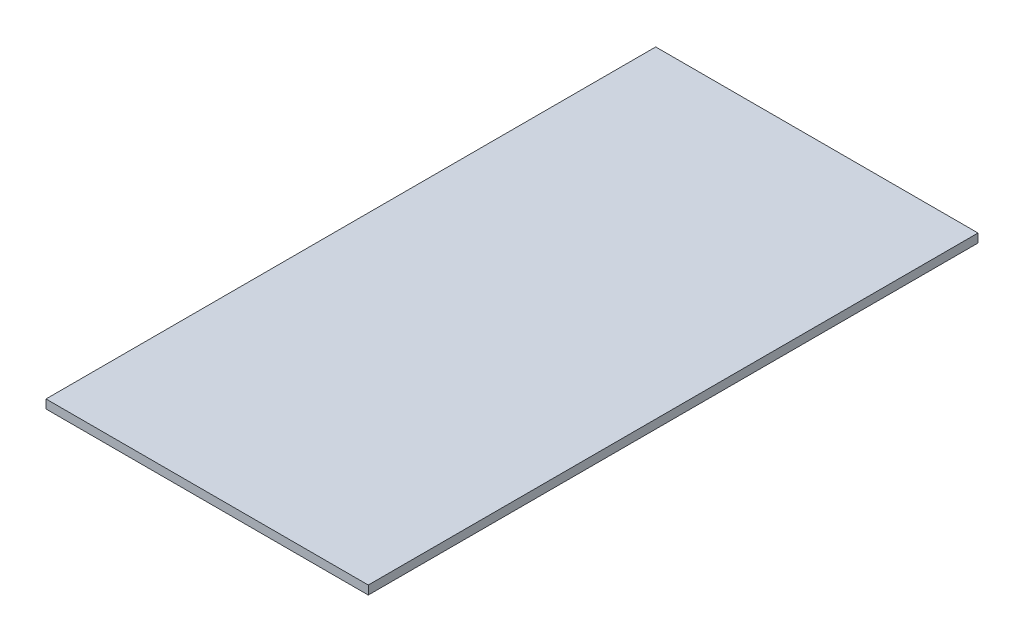
from build123d import *

# Parameters (mm, degrees)
SKETCH1_W           = 939.8
SKETCH1_H           = 1778
BOSS_EXTRUDE1_DEPTH = 25.4


with BuildPart() as part:
    # Sketch1 → Boss-Extrude1 (new body)
    with BuildSketch(Plane(origin=(0, 0, 0), x_dir=(1, 0, 0), z_dir=(0, 1, 0))):
        Rectangle(SKETCH1_W, SKETCH1_H)
    extrude(amount=BOSS_EXTRUDE1_DEPTH)


solid = part.part
